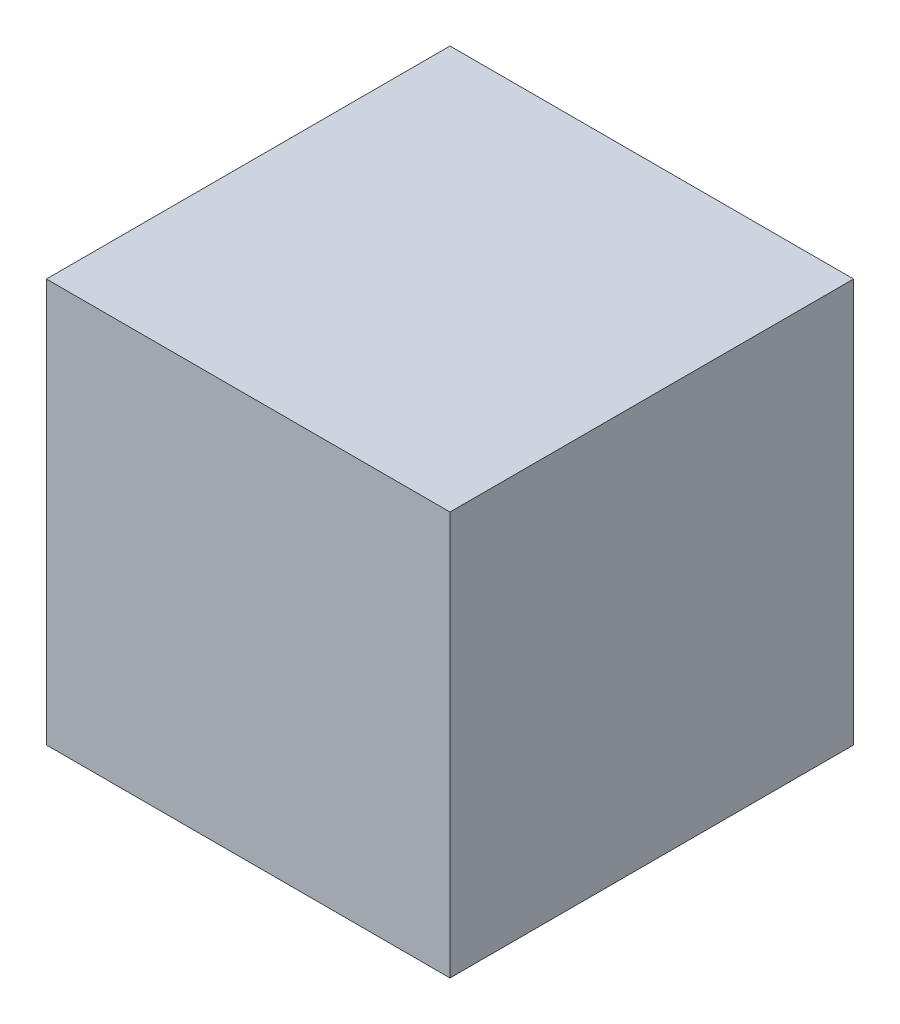
from build123d import *

# Parameters (mm, degrees)
SKETCH1_W           = 457.2
SKETCH1_H           = 457.2
BOSS_EXTRUDE1_DEPTH = 457.2


with BuildPart() as part:
    # Sketch1 → Boss-Extrude1 (new body)
    with BuildSketch(Plane(origin=(0, 0, 0), x_dir=(1, 0, 0), z_dir=(0, 1, 0))):
        with Locations((203.777911124, 203.544839867)):
            Rectangle(SKETCH1_W, SKETCH1_H)
    extrude(amount=BOSS_EXTRUDE1_DEPTH)


solid = part.part
